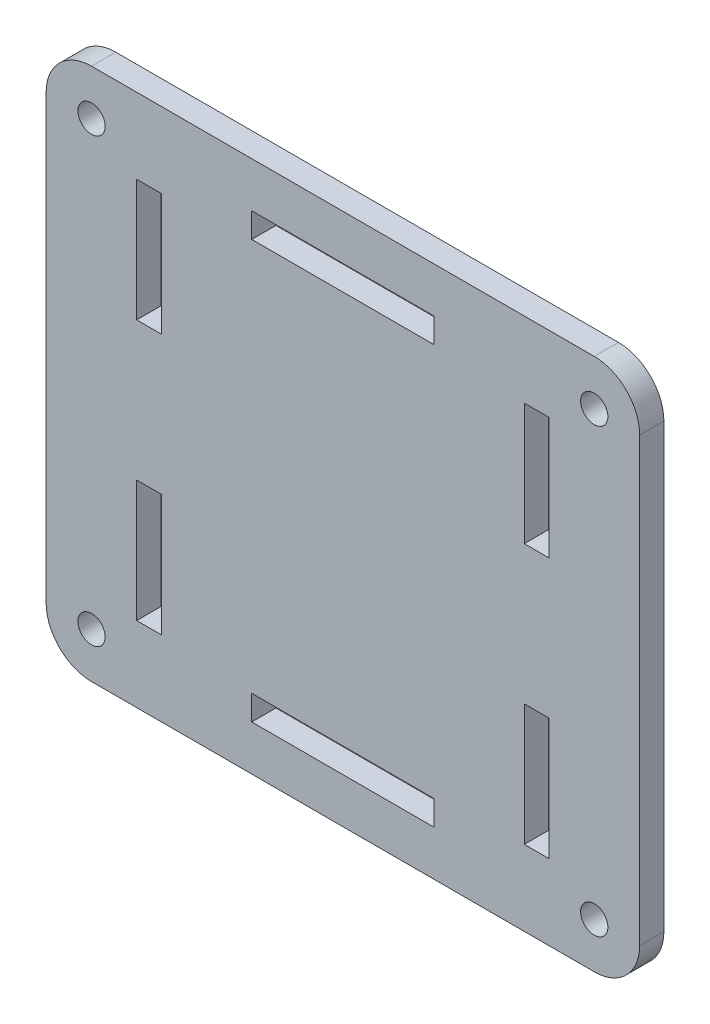
from build123d import *

# Parameters (mm, degrees)
SKETCH_1_W         = 88
SKETCH_1_H         = 98
SKETCH_1_W_2       = 4.1
SKETCH_1_H_2       = 30.1
SKETCH_1_W_3       = 20.1
SKETCH_1_H_3       = 4.1
EXTRUDE_1_DEPTH    = 4
HOLE_WIZARD_M4_1_D = 4.5
FILLET_3_R         = 7.5


with BuildPart() as part:
    # ｽｹｯﾁ1 → ﾎﾞｽ - 押し出し1 (new body)
    with BuildSketch(Plane(origin=(0, 0, 0), x_dir=(0, 1, 0), z_dir=(0, 0, 1))):
        with Locations((44, 49)):
            Rectangle(SKETCH_1_W, SKETCH_1_H)
        with Locations((78.5, 49)):
            Rectangle(SKETCH_1_W_2, SKETCH_1_H_2, mode=Mode.SUBTRACT)
        with Locations((22.5, 81)):
            Rectangle(SKETCH_1_W_3, SKETCH_1_H_3, mode=Mode.SUBTRACT)
        with Locations((65.5, 81)):
            Rectangle(SKETCH_1_W_3, SKETCH_1_H_3, mode=Mode.SUBTRACT)
        with Locations((22.5, 17)):
            Rectangle(SKETCH_1_W_3, SKETCH_1_H_3, mode=Mode.SUBTRACT)
        with Locations((65.5, 17)):
            Rectangle(SKETCH_1_W_3, SKETCH_1_H_3, mode=Mode.SUBTRACT)
        with Locations((9.5, 49)):
            Rectangle(SKETCH_1_W_2, SKETCH_1_H_2, mode=Mode.SUBTRACT)
    extrude(amount=EXTRUDE_1_DEPTH)

    # M4 すきま穴1 (through all)
    with Locations(Plane.XY.offset(4)):
        with Locations((-90.5, 80.5), (-7.5, 80.5), (-7.5, 7.5), (-90.5, 7.5)):
            Hole(HOLE_WIZARD_M4_1_D / 2)

    # ﾌｨﾚｯﾄ3
    fillet_3_edges = [part.edges().sort_by_distance(p)[0] for p in [
        (-98, 0, 2),
        (-98, 88, 2),
        (0, 88, 2),
        (0, 0, 2),
    ]]
    fillet(fillet_3_edges, radius=FILLET_3_R)


solid = part.part
